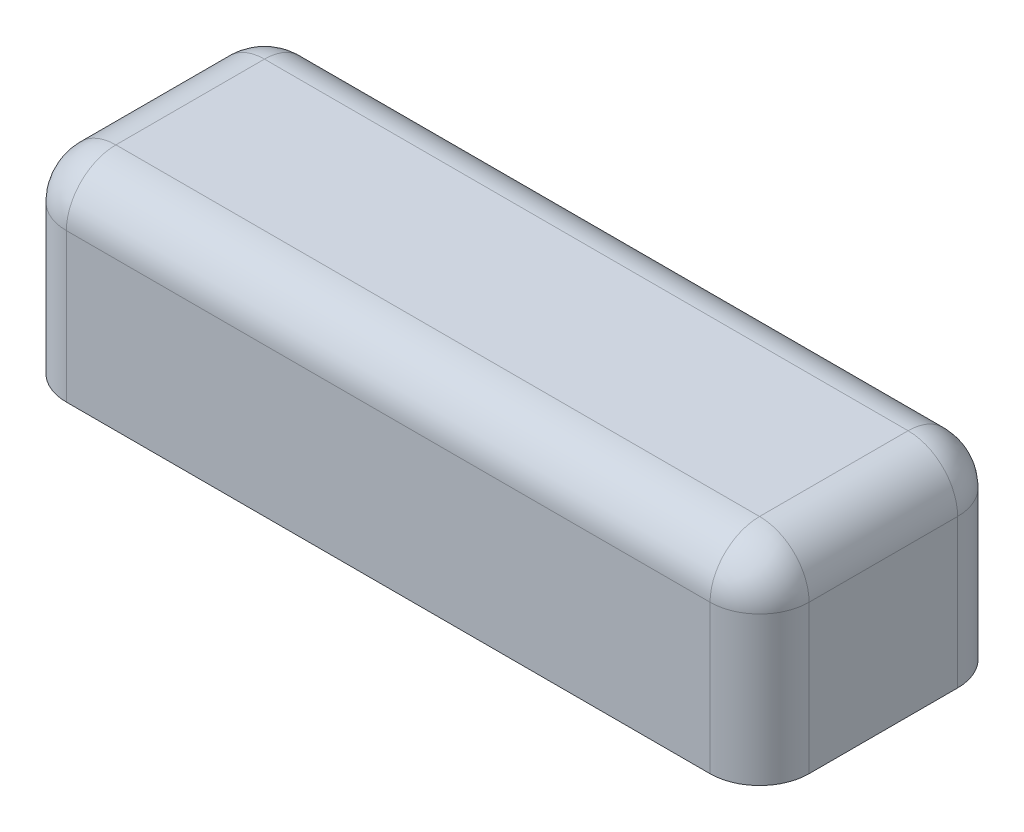
from build123d import *

# Parameters (mm, degrees)
SKETCH2_W           = 15
SKETCH2_H           = 5
BOSS_EXTRUDE1_DEPTH = 4
FILLET1_R           = 1


with BuildPart() as part:
    # Sketch2 → Boss-Extrude1 (new body)
    with BuildSketch(Plane(origin=(0, 0, 0), x_dir=(1, 0, 0), z_dir=(0, 1, 0))):
        with Locations((26.902702014, -48.335295526)):
            Rectangle(SKETCH2_W, SKETCH2_H)
    extrude(amount=BOSS_EXTRUDE1_DEPTH)

    # Fillet1
    fillet1_edges = [part.edges().sort_by_distance(p)[0] for p in [
        (34.402702014, 4, 48.335295526),
        (26.902702014, 4, 45.835295526),
        (19.402702014, 4, 48.335295526),
        (19.402702014, 2, 45.835295526),
        (34.402702014, 2, 45.835295526),
        (34.402702014, 2, 50.835295526),
        (19.402702014, 2, 50.835295526),
        (26.902702014, 4, 50.835295526),
    ]]
    fillet(fillet1_edges, radius=FILLET1_R)


solid = part.part
